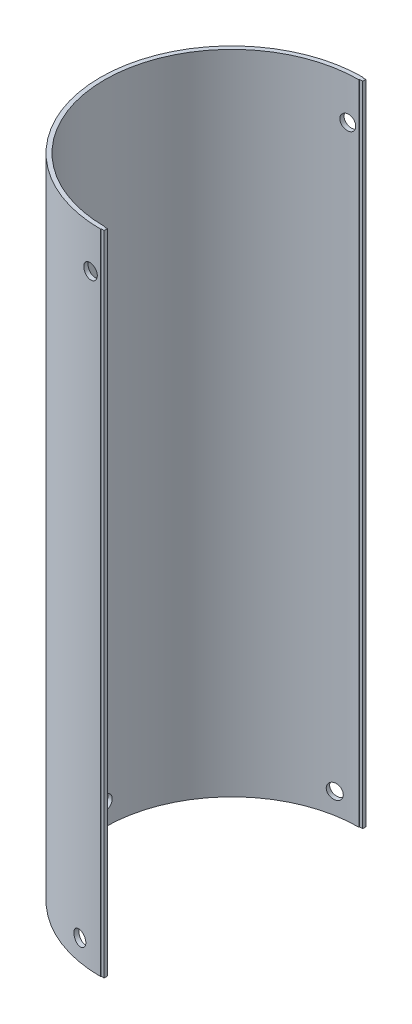
from build123d import *

# Parameters (mm, degrees)
BOSS_EXTRUDE1_DEPTH     = 308
CUT_EXTRUDE1_START      = -62.5
SKETCH4_R               = 3.5
CUT_EXTRUDE1_DEPTH      = 2.111341
CIRPATTERN2_COUNT       = 2
CIRPATTERN2_ANGLE       = 80
MIRROR1_START           = -62.5
MIRROR1_COPY_1_SKETCH_R = 3.5
MIRROR1_COPY_1_DEPTH    = 2.111341
MIRROR1_COPY_2_SKETCH_R = 3.5
MIRROR1_COPY_2_DEPTH    = 2.111341
SKETCH5_R               = 3.5
CUT_EXTRUDE2_DEPTH      = 5


with BuildPart() as part:
    # Sketch3 → Boss-Extrude1 (new body)
    with BuildSketch(Plane(origin=(0, 0, 0), x_dir=(1, 0, 0), z_dir=(0, 1, 0))):
        with BuildLine():
            Line((0, -60.49), (0, -60.75))
            Line((0, -60.75), (1.5, -60.75))
            Line((1.5, -60.75), (1.5, -62.25))
            Line((1.5, -62.25), (0, -62.25))
            Line((0, -62.25), (0, -62.5))
            ThreePointArc((0, -62.5), (-62.5, 0), (0, 62.5))
            Line((0, 62.5), (0, 62.25))
            Line((0, 62.25), (1.5, 62.25))
            Line((1.5, 62.25), (1.5, 60.75))
            Line((1.5, 60.75), (0, 60.75))
            Line((0, 60.75), (0, 60.49))
            ThreePointArc((0, 60.49), (-60.49, 0), (0, -60.49))
        make_face()
    extrude(amount=BOSS_EXTRUDE1_DEPTH)

    # Sketch4 → Cut-Extrude1 (cut)
    with BuildSketch(Plane(origin=(0, 0, 0), x_dir=(0, 0, -1), z_dir=(1, 0, 0)).offset(CUT_EXTRUDE1_START)):
        with Locations((0, 10)):
            Circle(SKETCH4_R)
    cut_extrude1 = extrude(amount=CUT_EXTRUDE1_DEPTH, mode=Mode.SUBTRACT)

    # CirPattern2: Cut-Extrude1 ×2 about axis
    cirpattern2_axis = Axis((0, 0, 0), (0, 1, 0))
    for i in range(1, CIRPATTERN2_COUNT):
        add(cut_extrude1.rotate(cirpattern2_axis, i * CIRPATTERN2_ANGLE / (CIRPATTERN2_COUNT - 1)), mode=Mode.SUBTRACT)

    # Mirror1 copy 1 sketch → Mirror1 copy 1 (cut)
    with BuildSketch(Plane(origin=(0, 0, 0), x_dir=(-0.984807753, 0, 0.173648178), z_dir=(0.173648178, 0, 0.984807753)).offset(MIRROR1_START)):
        with Locations((0, -10)):
            Circle(MIRROR1_COPY_1_SKETCH_R)
    extrude(amount=MIRROR1_COPY_1_DEPTH, mode=Mode.SUBTRACT)

    # Mirror1 copy 2 sketch → Mirror1 copy 2 (cut)
    with BuildSketch(Plane(origin=(0, 0, 0), x_dir=(0, 0, 1), z_dir=(1, 0, 0)).offset(MIRROR1_START)):
        with Locations((0, -10)):
            Circle(MIRROR1_COPY_2_SKETCH_R)
    extrude(amount=MIRROR1_COPY_2_DEPTH, mode=Mode.SUBTRACT)

    # Sketch5 → Cut-Extrude2 (cut, symmetric)
    with BuildSketch(Plane(origin=(0, 0, -62.5), x_dir=(-1, 0, 0), z_dir=(0, 0, -1))):
        with Locations((5, 288)):
            Circle(SKETCH5_R)
    cut_extrude2 = extrude(amount=CUT_EXTRUDE2_DEPTH, both=True, mode=Mode.SUBTRACT)

    # Mirror2: Cut-Extrude2 across plane
    add(cut_extrude2.mirror(Plane.XY), mode=Mode.SUBTRACT)


solid = part.part
